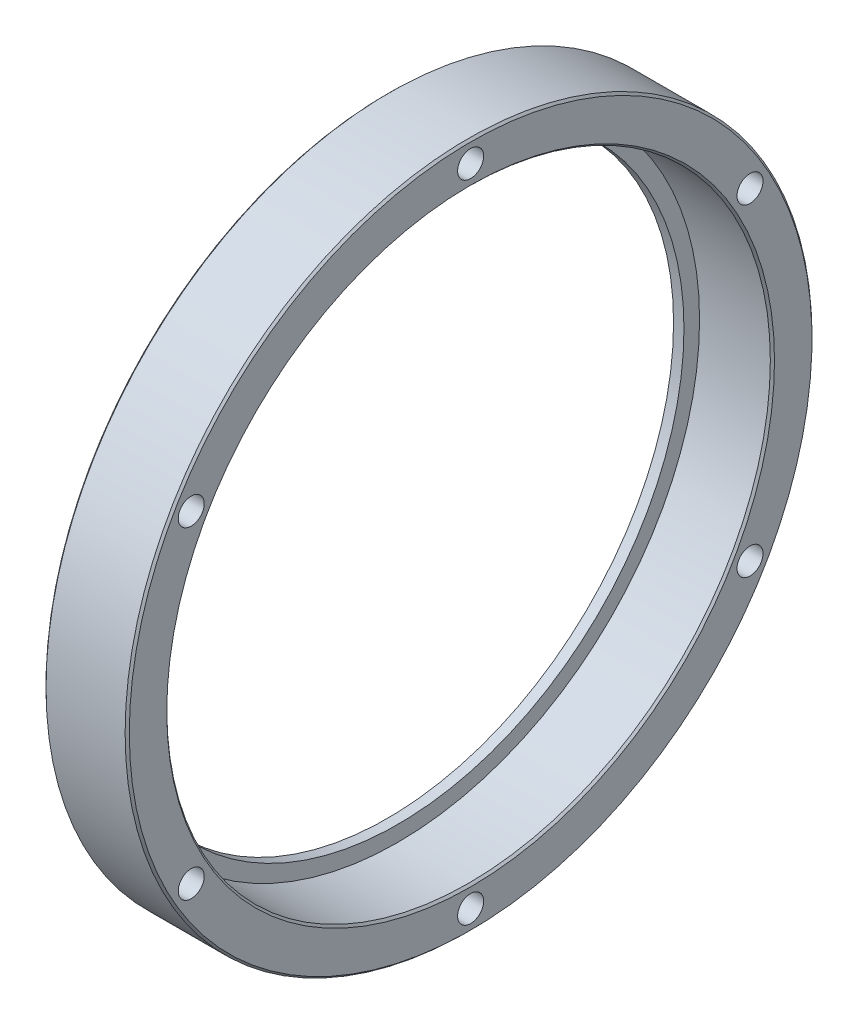
from build123d import *

# Parameters (mm, degrees)
HOLE_WIZARD_M3_1_D       = 2.5
PATTERN_CIRCULAR_1_COUNT = 6
CHAMFER_1_SIZE           = 0.2


with BuildPart() as part:
    # 草图1 → 旋转1 (revolve)
    with BuildSketch(Plane.XY):
        Polygon((0, 27.5), (0, 33), (8, 33), (8, 29), (1, 29), (1, 27.5), align=None)
    revolve(axis=Axis((0, 0, 0), (1, 0, 0)))

    # M3 螺纹孔1 (through all)
    with Locations(Plane(origin=(8, 0, 0), x_dir=(0, 0, -1), z_dir=(1, 0, 0))):
        with Locations((0, 31)):
            hole_wizard_m3_1 = Hole(HOLE_WIZARD_M3_1_D / 2)

    # 阵列(圆周)1: M3 螺纹孔1 ×6 about axis
    pattern_circular_1_axis = Axis((0, 0, 0), (1, 0, 0))
    for i in range(1, PATTERN_CIRCULAR_1_COUNT):
        add(hole_wizard_m3_1.rotate(pattern_circular_1_axis, i * 360 / PATTERN_CIRCULAR_1_COUNT), mode=Mode.SUBTRACT)

    # 倒角1
    chamfer_1_edges = [part.edges().sort_by_distance(p)[0] for p in [
        (8, -29, 0),
        (8, -33, 0),
        (0, -33, 0),
    ]]
    chamfer(chamfer_1_edges, length=CHAMFER_1_SIZE)


solid = part.part
